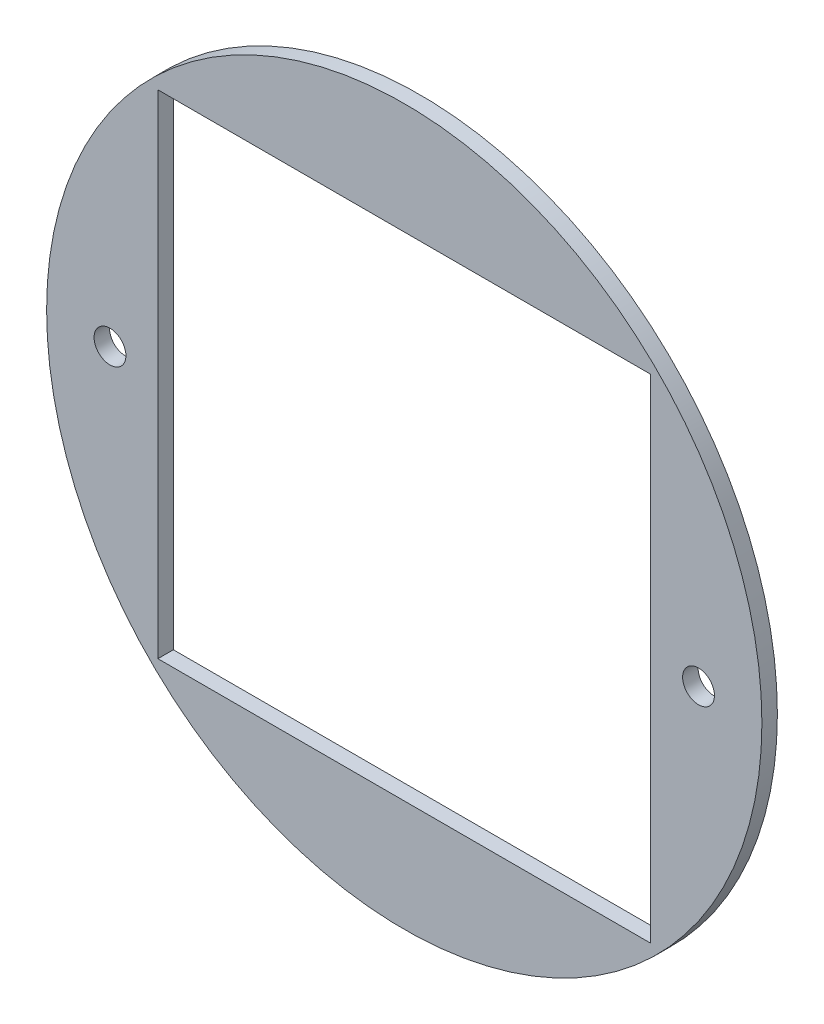
from build123d import *

# Parameters (mm, degrees)
SKETCH1_R               = 73.3171
BOSS_EXTRUDE1_DEPTH     = 3.175
F_1_4_CLEARANCE_HOLE1_D = 6.5278
SKETCH4_W               = 100.99999993
SKETCH4_H               = 100.99999993
CUT_EXTRUDE1_DEPTH      = 1
CUT_EXTRUDE1_DEPTH_BACK = 4.175


with BuildPart() as part:
    # Sketch1 → Boss-Extrude1 (new body)
    with BuildSketch(Plane.XY):
        Circle(SKETCH1_R)
    extrude(amount=BOSS_EXTRUDE1_DEPTH)

    # 1/4 Clearance Hole1 (through all)
    with Locations(Plane.XY.offset(3.175)):
        with Locations((-60.325, 0), (60.325, 0)):
            Hole(F_1_4_CLEARANCE_HOLE1_D / 2)

    # Sketch4 → Cut-Extrude1 (cut, two sides)
    with BuildSketch(Plane.XY.offset(3.175)) as cut_extrude1_sk:
        Rectangle(SKETCH4_W, SKETCH4_H)
    extrude(amount=CUT_EXTRUDE1_DEPTH, mode=Mode.SUBTRACT)
    extrude(cut_extrude1_sk.sketch, amount=-CUT_EXTRUDE1_DEPTH_BACK, mode=Mode.SUBTRACT)


solid = part.part
